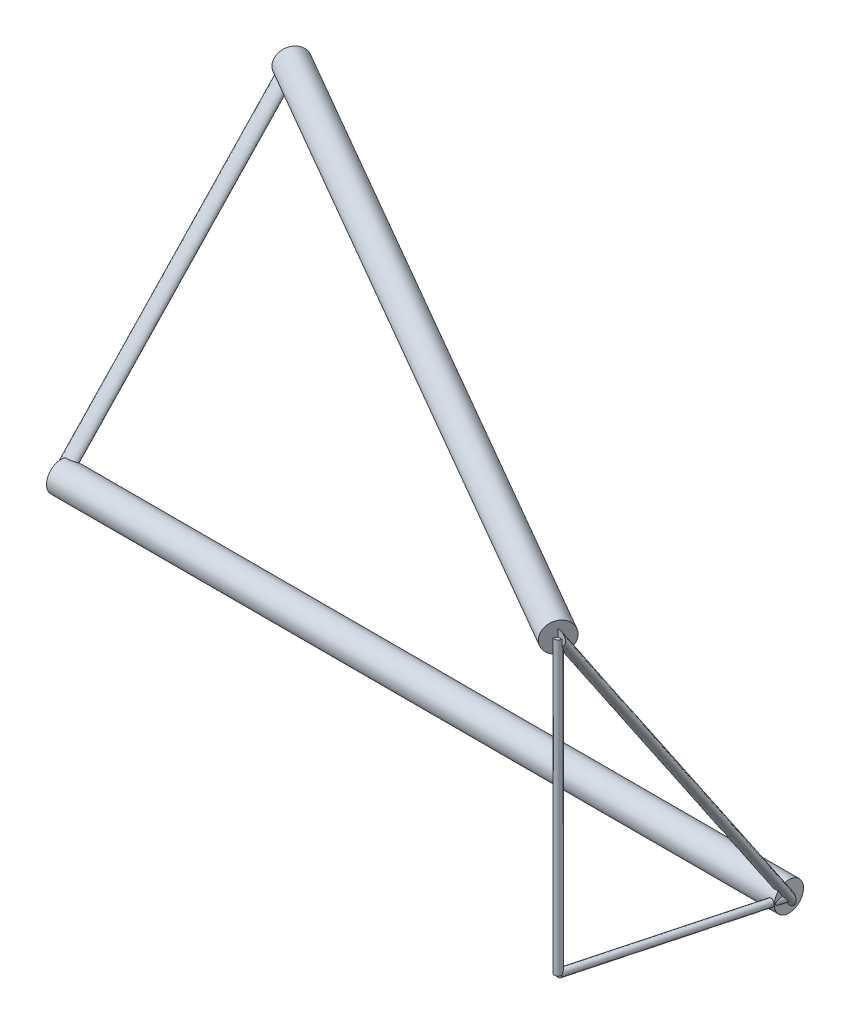
from build123d import *

# Parameters (mm, degrees)
BOSS_EXTRUDE1_DEPTH      = 5
BOSS_EXTRUDE1_DEPTH_BACK = 5
SKETCH21_R               = 0.2
BOSS_EXTRUDE2_DEPTH      = 5
BOSS_EXTRUDE2_DEPTH_BACK = 5
SKETCH32_R               = 0.2
SKETCH48_R               = 0.1
SKETCH49_R               = 0.1
SKETCH53_R               = 0.05
SKETCH55_R               = 0.05


with BuildPart() as part:
    # Sketch21 → Boss-Extrude1 (new, two sides: drawn at the far end of the back side and taken through both)
    with BuildSketch(Plane(origin=(0, 0, 0), x_dir=(0, 0, -1), z_dir=(1, 0, 0)).offset(-BOSS_EXTRUDE1_DEPTH_BACK)):
        Circle(SKETCH21_R)
    extrude(amount=BOSS_EXTRUDE1_DEPTH + BOSS_EXTRUDE1_DEPTH_BACK)



with BuildPart() as body_2:
    # Sketch32 → Boss-Extrude2 (new, two sides: drawn at the far end of the back side and taken through both)
    with BuildSketch(Plane(origin=(0, 0, 0), x_dir=(0.49999999999999384, 0, -0.8660254037844423), z_dir=(0.8660254037844421, 0, 0.4999999999999938)).offset(-BOSS_EXTRUDE2_DEPTH_BACK)):
        with Locations((0, 4)):
            Circle(SKETCH32_R)
    extrude(amount=BOSS_EXTRUDE2_DEPTH + BOSS_EXTRUDE2_DEPTH_BACK)


with BuildPart() as part_1:
    add(part.part)

    add(body_2.part)  # Sweep1 merges body 2
    # Sweep1: sweep along a path in Sketch35
    with BuildLine(Plane(origin=(-4.665063509, 0, -1.25), x_dir=(-0.2588190451025216, 9.520411571258269e-14, 0.9659258262890681), z_dir=(-0.9659258262890681, -9.227366390944018e-13, -0.2588190451025216))) as sweep1_path:
        Line((-1.294095225, 4), (1.294095226, 0))
    # Sketch48 → Sweep1 (sweep)
    with BuildSketch(Plane.XY):
        with Locations((-5, 0)):
            Circle(SKETCH48_R)
    sweep(path=sweep1_path.line)

    # Sweep2: sweep along a path in Sketch39
    with BuildLine(Plane(origin=(4.665063509, 0, 1.25), x_dir=(0.25881904510252174, -9.816861385133173e-14, -0.9659258262890681), z_dir=(0.965925826289068, 9.15622402506253e-13, 0.2588190451025217))) as sweep2_path:
        Line((-1.294095226, 4), (1.294095226, 0))
    # Sketch49 → Sweep2 (sweep)
    with BuildSketch(Plane.XY):
        with Locations((5, 0)):
            Circle(SKETCH49_R)
    sweep(path=sweep2_path.line)

    # Sweep3: sweep along a path in Sketch46
    with BuildLine(Plane(origin=(4.665063509, 0, 1.25), x_dir=(0.25881904510252174, -9.816861385133173e-14, -0.9659258262890681), z_dir=(0.965925826289068, 9.15622402506253e-13, 0.2588190451025217))) as sweep3_path:
        Line((-1.294095226, 4), (-1.294095226, 0))
    # Sketch53 → Sweep3 (sweep)
    with BuildSketch(Plane(origin=(0, 0, 0), x_dir=(1, 0, 0), z_dir=(0, 1, 0))):
        with Locations((4.330127019, -2.5)):
            Circle(SKETCH53_R)
    sweep(path=sweep3_path.line)

    # Sweep4: sweep along a path in Sketch45
    with BuildLine(Plane(origin=(4.665063509, 0, 1.25), x_dir=(0.25881904510252174, -9.816861385133173e-14, -0.9659258262890681), z_dir=(0.965925826289068, 9.15622402506253e-13, 0.2588190451025217))) as sweep4_path:
        Line((1.294095226, 0), (-1.294095226, 0))
    # Sketch55 → Sweep4 (sweep)
    with BuildSketch(Plane.XY):
        with Locations((5, 0)):
            Circle(SKETCH55_R)
    sweep(path=sweep4_path.line)


solid = part_1.part
